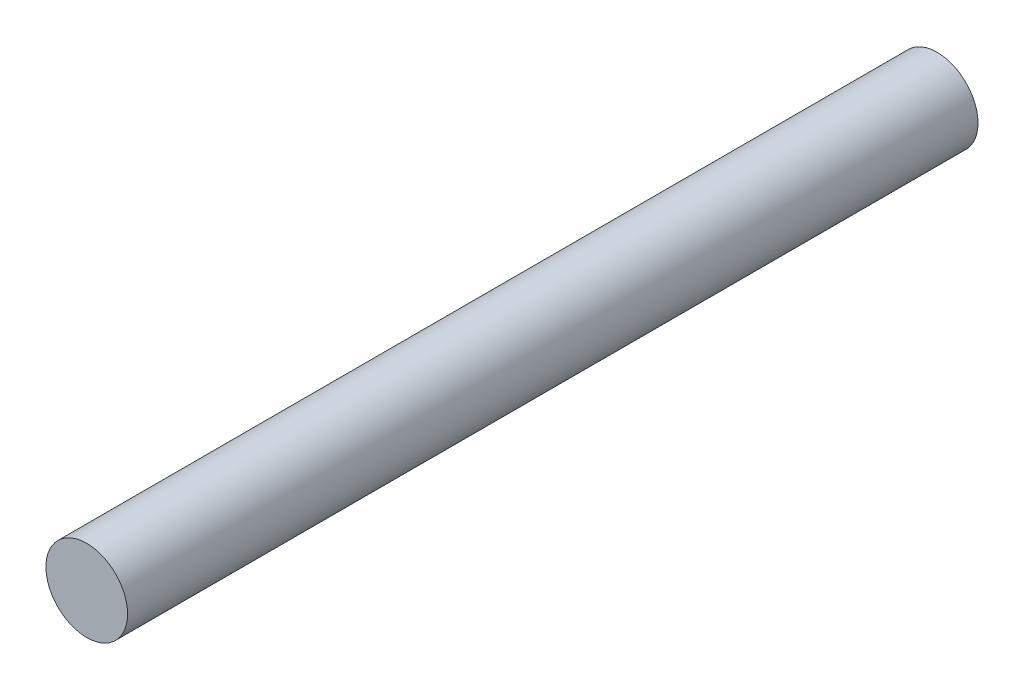
from build123d import *

# Parameters (mm, degrees)
SKETCH2_R           = 6
BOSS_EXTRUDE1_DEPTH = 125


with BuildPart() as part:
    # Sketch2 → Boss-Extrude1 (new body)
    with BuildSketch(Plane.XY):
        Circle(SKETCH2_R)
    extrude(amount=BOSS_EXTRUDE1_DEPTH)


solid = part.part
